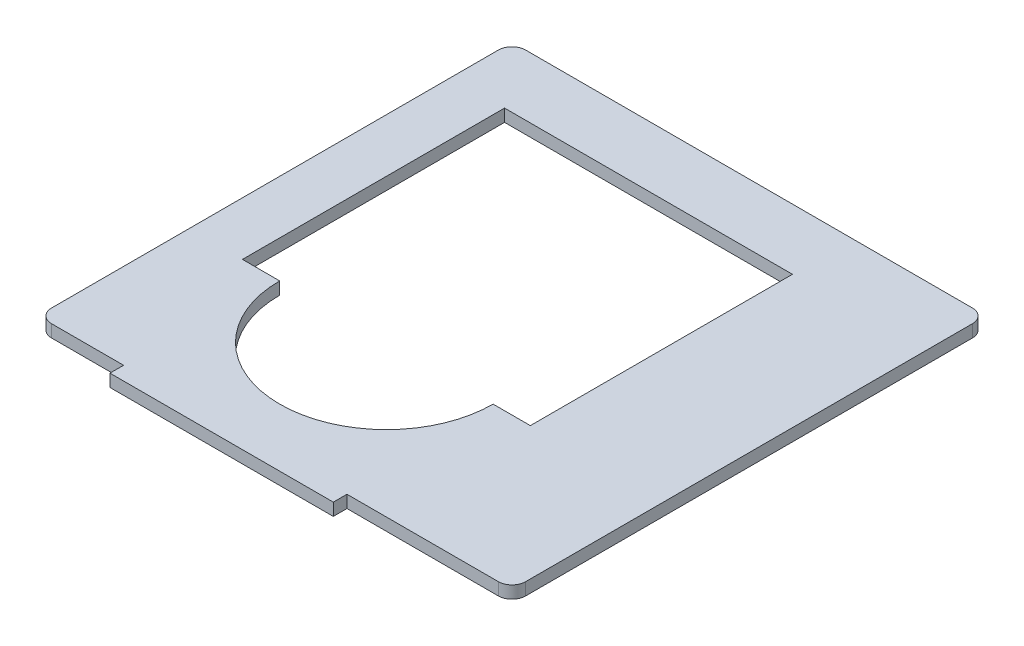
from build123d import *

# Parameters (mm, degrees)
BOSS_EXTRUDE1_DEPTH = 2.5
CUT_EXTRUDE1_DEPTH  = 6
SKETCH3_W           = 90
SKETCH3_H           = 5.5
BOSS_EXTRUDE2_DEPTH = 5


with BuildPart() as part:
    # Sketch1 → Boss-Extrude1 (new body, symmetric)
    with BuildSketch(Plane(origin=(0, 0, 0), x_dir=(1, 0, 0), z_dir=(0, 1, 0))):
        with BuildLine():
            Line((90, 95.5), (-90, 95.5))
            ThreePointArc((-90, 95.5), (-93.889087297, 93.889087297), (-95.5, 90))
            Line((-95.5, 90), (-95.5, -90))
            ThreePointArc((-95.5, -90), (-93.889087297, -93.889087297), (-90, -95.5))
            Line((-90, -95.5), (90, -95.5))
            ThreePointArc((90, -95.5), (93.889087297, -93.889087297), (95.5, -90))
            Line((95.5, -90), (95.5, 90))
            ThreePointArc((95.5, 90), (93.889087297, 93.889087297), (90, 95.5))
        make_face()
    extrude(amount=BOSS_EXTRUDE1_DEPTH, both=True)

    # Sketch2 → Cut-Extrude1 (cut, through all)
    with BuildSketch(Plane(origin=(0, 2.5, 0), x_dir=(1, 0, 0), z_dir=(0, 1, 0))):
        with BuildLine():
            Line((42, 71), (-74, 71))
            Line((-74, 71), (-74, -34.610229671))
            Line((-74, -34.610229671), (-59, -34.610229671))
            ThreePointArc((-59, -34.610229671), (-16, -77.610229671), (27, -34.610229671))
            Line((27, -34.610229671), (42, -34.610229671))
            Line((42, -34.610229671), (42, 71))
        make_face()
    extrude(amount=-CUT_EXTRUDE1_DEPTH, mode=Mode.SUBTRACT)

    # Sketch3 → Boss-Extrude2 (add)
    with BuildSketch(Plane(origin=(0, 2.5, 0), x_dir=(1, 0, 0), z_dir=(0, 1, 0))):
        with Locations((-16, -98.25)):
            Rectangle(SKETCH3_W, SKETCH3_H)
    extrude(amount=-BOSS_EXTRUDE2_DEPTH)


solid = part.part
